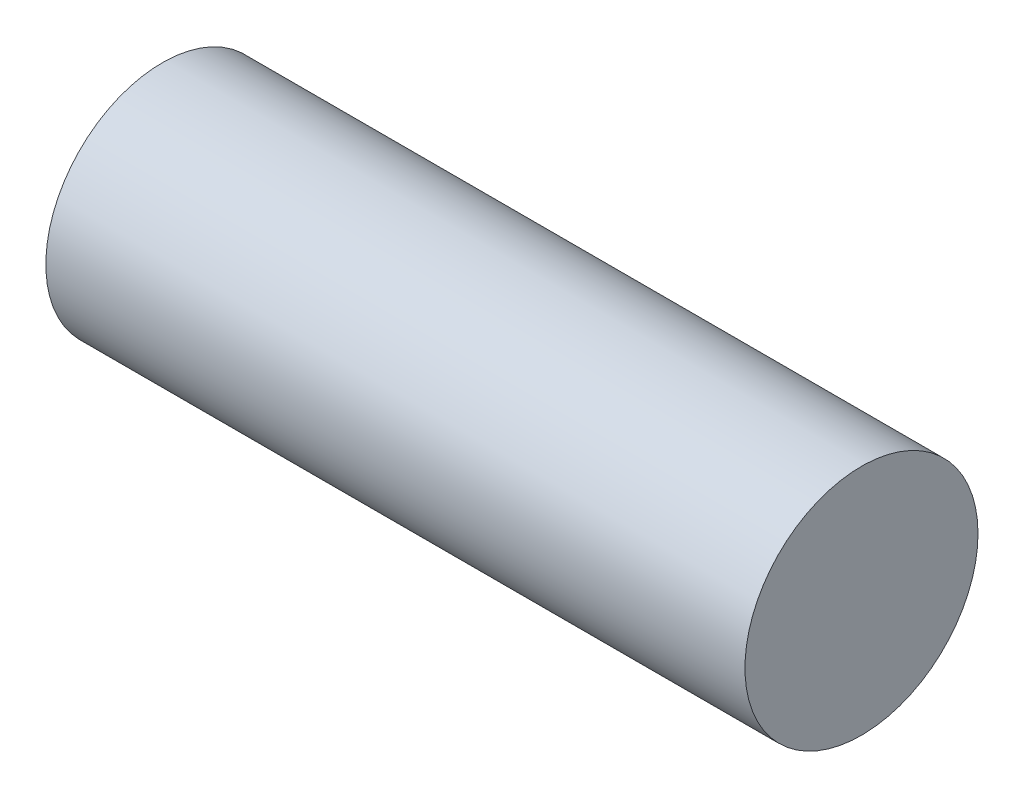
from build123d import *

# Parameters (mm, degrees)
CROQUIS1_R              = 10
SALIENTE_EXTRUIR1_DEPTH = 30


with BuildPart() as part:
    # Croquis1 → Saliente-Extruir1 (new body, symmetric)
    with BuildSketch(Plane(origin=(0, 0, 0), x_dir=(0, 0, -1), z_dir=(1, 0, 0))):
        Circle(CROQUIS1_R)
    extrude(amount=SALIENTE_EXTRUIR1_DEPTH, both=True)


solid = part.part
